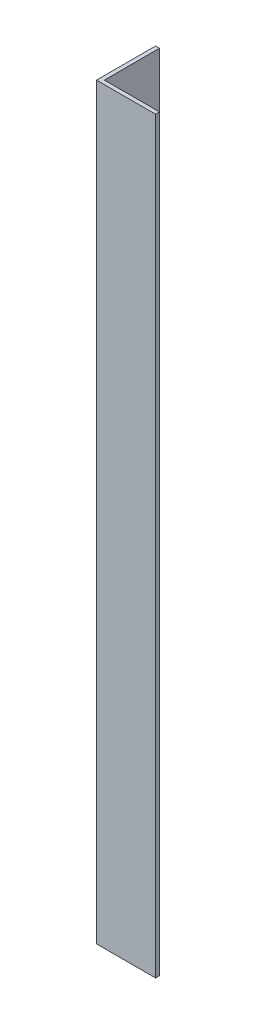
from build123d import *

# Parameters (mm, degrees)
EXTRUDE_1_DEPTH = 190


with BuildPart() as part:
    # Эскиз1 → Бобышка-Вытянуть1 (new body)
    with BuildSketch(Plane(origin=(0, 0, 0), x_dir=(1, 0, 0), z_dir=(0, 1, 0))):
        Polygon((0, 0), (0, 15), (1, 15), (1, 1), (15, 1), (15, 0), align=None)
    extrude(amount=EXTRUDE_1_DEPTH)


solid = part.part
